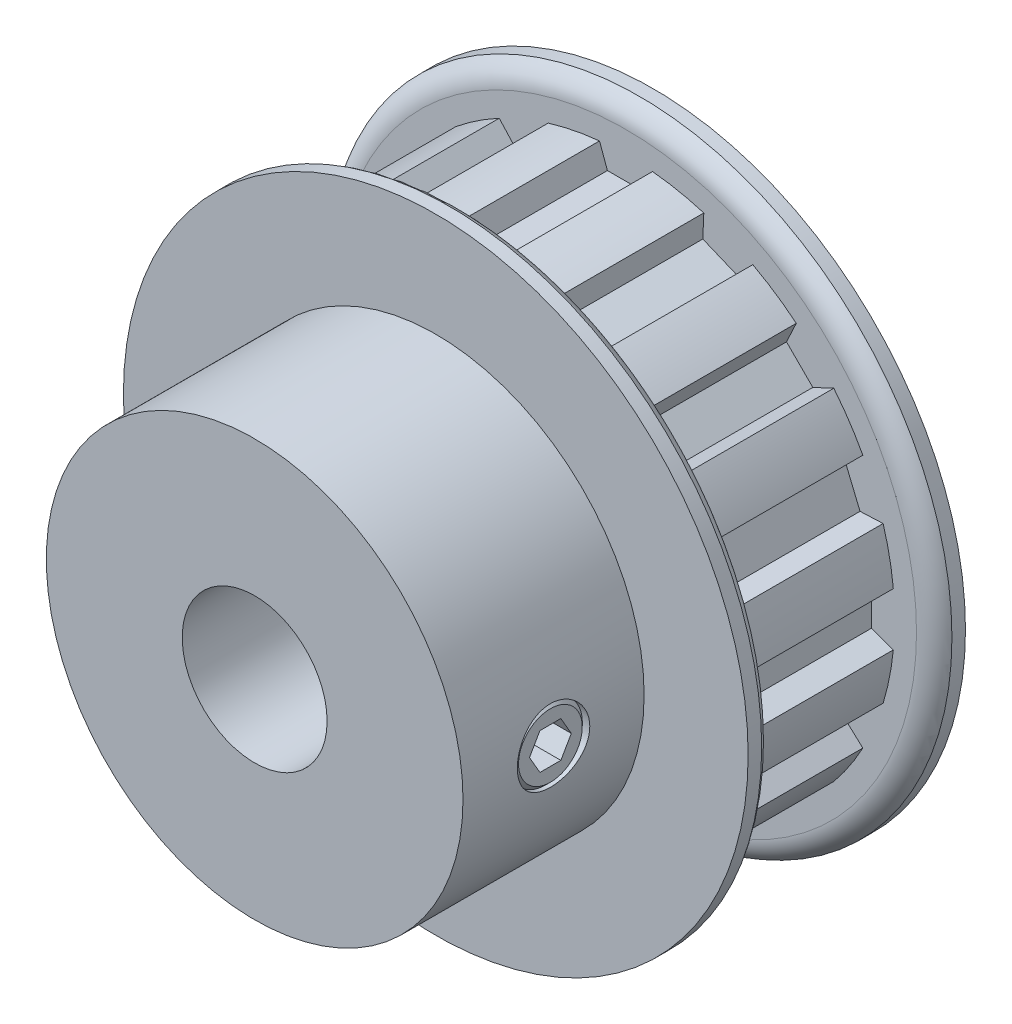
from build123d import *

# Parameters (mm, degrees)
CUT_EXTRUDE1_START = -0.7874
CUT_EXTRUDE1_DEPTH = 14.3002
CIRPATTERN1_COUNT  = 16
SKETCH4_R          = 3.175
CUT_EXTRUDE2_DEPTH = 43.478219515
CUT_EXTRUDE3_DEPTH = 2.38125


with BuildPart() as part:
    # Sketch2 → Revolve1 (revolve)
    with BuildSketch(Plane(origin=(0, 0, 0), x_dir=(0, 0, -1), z_dir=(1, 0, 0)), mode=Mode.PRIVATE) as revolve1_sk:
        with BuildLine():
            Line((-17.4625, 6.35), (17.4625, 6.35))
            Line((17.4625, 6.35), (17.4625, 27.3812))
            Line((17.4625, 27.3812), (16.27505, 27.3812))
            ThreePointArc((16.27505, 27.3812), (15.408504076, 26.591481572), (15.0876, 25.463839073))
            Line((15.0876, 25.463839073), (15.0876, 23.546478146))
            Line((15.0876, 23.546478146), (0.7874, 23.546478146))
            Line((0.7874, 23.546478146), (0.7874, 25.463839073))
            ThreePointArc((0.7874, 25.463839073), (0.466495924, 26.591481572), (-0.40005, 27.3812))
            Line((-0.40005, 27.3812), (-1.5875, 27.3812))
            Line((-1.5875, 27.3812), (-1.5875, 18.2626))
            Line((-1.5875, 18.2626), (-17.4625, 18.2626))
            Line((-17.4625, 18.2626), (-17.4625, 6.35))
        make_face()
    revolve(revolve1_sk.sketch.rotate(Axis((0, 0, 17.4625), (0, 0, -1)), 90), axis=Axis((0, 0, 17.4625), (0, 0, -1)))

    # Sketch3 → Cut-Extrude1 (cut)
    with BuildSketch(Plane.XY.offset(CUT_EXTRUDE1_START)):
        with BuildLine():
            Line((-1.630736704, 21.5265), (1.630736704, 21.5265))
            Line((1.630736704, 21.5265), (2.3241, 23.4315))
            ThreePointArc((2.3241, 23.4315), (0, 23.546478146), (-2.3241, 23.4315))
            Line((-2.3241, 23.4315), (-1.630736704, 21.5265))
        make_face()
    cut_extrude1 = extrude(amount=-CUT_EXTRUDE1_DEPTH, mode=Mode.SUBTRACT)

    # CirPattern1: Cut-Extrude1 ×16 about axis
    cirpattern1_axis = Axis((0, 0, 0), (0, 0, 1))
    for i in range(1, CIRPATTERN1_COUNT):
        add(cut_extrude1.rotate(cirpattern1_axis, i * 360 / CIRPATTERN1_COUNT), mode=Mode.SUBTRACT)

    # Sketch4 → Cut-Extrude2 (cut, through all)
    with BuildSketch(Plane(origin=(0, 0, 0), x_dir=(0, -1, 0), z_dir=(1, 0, 0))):
        with Locations(Location((0, -9.525, 0), (0, 0, 270))):
            Circle(SKETCH4_R)
    extrude(amount=CUT_EXTRUDE2_DEPTH, mode=Mode.SUBTRACT)

    # Sketch5 → Revolve2 (revolve)
    with BuildSketch(Plane.XY.offset(9.525)):
        Polygon((6.35, -2.794), (6.35, 0), (17.984491479, 0), (17.984491479, -2.794), (17.603491479, -3.175), (6.731, -3.175), align=None)
    revolve(axis=Axis((6.35, 0, 9.525), (1, 0, 0)))

    # Sketch6 → Cut-Extrude3 (cut)
    with BuildSketch(Plane(origin=(17.984491479, 5.384140679, 0), x_dir=(0, -1, 0), z_dir=(-1, 0, 0))):
        Polygon((5.384140679, 11.358087105), (3.796640679, 10.441543552), (3.796640679, 8.608456448), (5.384140679, 7.691912895), (6.971640679, 8.608456448), (6.971640679, 10.441543552), align=None)
    extrude(amount=CUT_EXTRUDE3_DEPTH, mode=Mode.SUBTRACT)


solid = part.part
